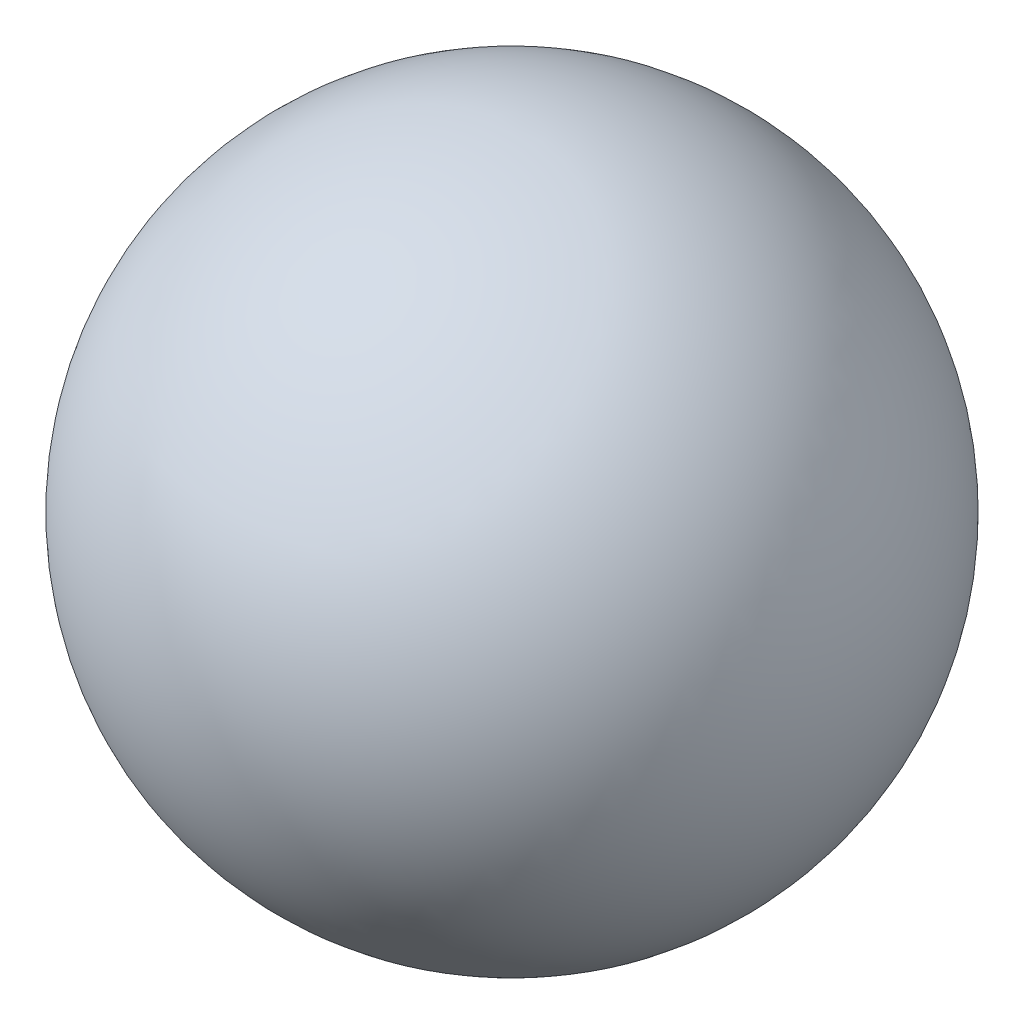
from build123d import *


with BuildPart() as part:
    # Esquisse1 → Révolution1 (revolve)
    with BuildSketch(Plane.XY):
        with BuildLine():
            Line((0, 22.25), (0, -22.25))
            ThreePointArc((0, -22.25), (22.25, 0), (0, 22.25))
        make_face()
    revolve(axis=Axis((0, -24.475, 0), (0, 1, 0)))


solid = part.part
